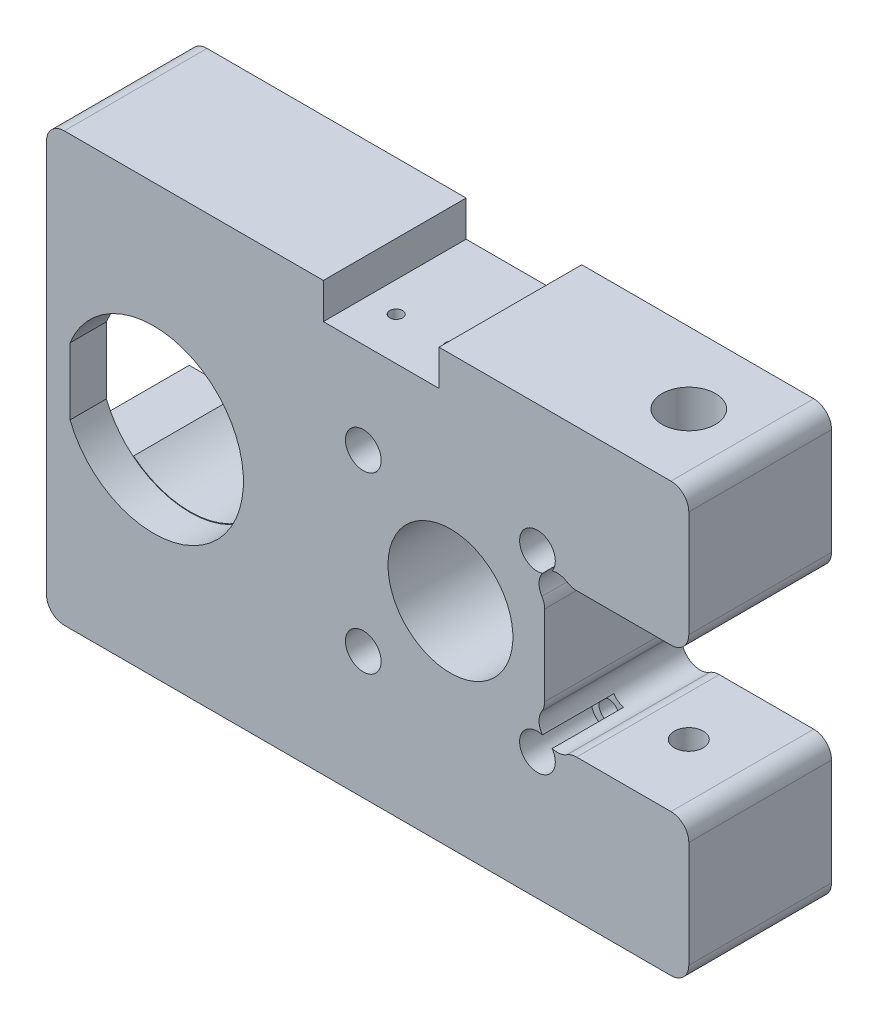
from build123d import *

# Parameters (mm, degrees)
SKETCH1_W           = 114.3
SKETCH1_H           = 76.2
BOSS_EXTRUDE1_DEPTH = 25.4
CUT_EXTRUDE1_DEPTH  = 6.477
CUT_EXTRUDE2_DEPTH  = 18.923
SKETCH4_W           = 20.574
SKETCH4_H           = 25.4
CUT_EXTRUDE3_DEPTH  = 6.35
CUT_EXTRUDE4_START  = -25.4
CUT_EXTRUDE4_DEPTH  = 25.4
CUT_EXTRUDE5_START  = -25.4
SKETCH6_R           = 1.75
SKETCH6_R_2         = 11.1125
CUT_EXTRUDE5_DEPTH  = 25.4
SKETCH8_R           = 3.175
CUT_EXTRUDE6_DEPTH  = 12.7
FILLET1_R           = 3.175
CUT_EXTRUDE7_START  = -76.2
SKETCH9_R           = 2.5796875
CUT_EXTRUDE7_DEPTH  = 76.2
SKETCH10_R          = 4.7625
CUT_EXTRUDE8_DEPTH  = 15.875
SKETCH11_R          = 4.7625
CUT_EXTRUDE9_DEPTH  = 15.875
FILLET2_R           = 3.175
SKETCH12_R          = 2.032
CUT_EXTRUDE10_DEPTH = 12.446
SKETCH13_R          = 1.35255
CUT_EXTRUDE11_DEPTH = 12.7
SKETCH14_R          = 1.143
CUT_EXTRUDE12_DEPTH = 12.7


with BuildPart() as part:
    # Sketch1 → Boss-Extrude1 (new body)
    with BuildSketch(Plane.XY):
        Rectangle(SKETCH1_W, SKETCH1_H)
    extrude(amount=BOSS_EXTRUDE1_DEPTH)

    # Sketch2 → Cut-Extrude1 (cut)
    with BuildSketch(Plane.XY.offset(25.4)):
        with BuildLine():
            Line((-52.959, 5.939202219), (-52.959, -5.939202219))
            ThreePointArc((-52.959, -5.939202219), (-22.098, 0), (-52.959, 5.939202219))
        make_face()
    extrude(amount=-CUT_EXTRUDE1_DEPTH, mode=Mode.SUBTRACT)

    # Sketch3 → Cut-Extrude2 (cut)
    with BuildSketch(Plane.XY.offset(18.923)):
        with BuildLine():
            Line((-17.276835078, 12.319), (-28.067, 12.319))
            ThreePointArc((-28.067, 12.319), (-38.1, 15.887694924), (-48.133, 12.319))
            Line((-48.133, 12.319), (-57.15, 12.319))
            Line((-57.15, 12.319), (-57.15, -12.319))
            Line((-57.15, -12.319), (-48.133, -12.319))
            ThreePointArc((-48.133, -12.319), (-38.1, -15.887694924), (-28.067, -12.319))
            Line((-28.067, -12.319), (-17.276835078, -12.319))
            ThreePointArc((-17.276835078, -12.319), (-12.782632352, -12.236367648), (-12.7, -7.742164922))
            Line((-12.7, -7.742164922), (-12.7, 7.742164922))
            ThreePointArc((-12.7, 7.742164922), (-12.782632352, 12.236367648), (-17.276835078, 12.319))
        make_face()
    extrude(amount=-CUT_EXTRUDE2_DEPTH, mode=Mode.SUBTRACT)

    # Sketch4 → Cut-Extrude3 (cut)
    with BuildSketch(Plane(origin=(0, 38.1, 0), x_dir=(1, 0, 0), z_dir=(0, 1, 0))):
        with Locations((2.413, -12.7)):
            Rectangle(SKETCH4_W, SKETCH4_H)
    extrude(amount=-CUT_EXTRUDE3_DEPTH, mode=Mode.SUBTRACT)

    # Sketch5 → Cut-Extrude4 (cut)
    with BuildSketch(Plane(origin=(0, 0, 0), x_dir=(-1, 0, 0), z_dir=(0, 0, -1)).offset(CUT_EXTRUDE4_START)):
        with BuildLine():
            Line((-36.075066976, -12.827), (-57.15, -12.827))
            Line((-57.15, -12.827), (-57.15, 12.827))
            Line((-57.15, 12.827), (-36.075066976, 12.827))
            ThreePointArc((-36.075066976, 12.827), (-31.451098719, 12.871901281), (-31.496, 8.247933024))
            Line((-31.496, 8.247933024), (-31.496, -8.247933024))
            ThreePointArc((-31.496, -8.247933024), (-31.451098719, -12.871901281), (-36.075066976, -12.827))
        make_face()
    extrude(amount=CUT_EXTRUDE4_DEPTH, mode=Mode.SUBTRACT)

    # Sketch6 → Cut-Extrude5 (cut)
    with BuildSketch(Plane(origin=(0, 0, 0), x_dir=(-1, 0, 0), z_dir=(0, 0, -1)).offset(CUT_EXTRUDE5_START)):
        with Locations((0.768, 15.5)):
            Circle(SKETCH6_R)
        with Locations((0.768, -15.5)):
            Circle(SKETCH6_R)
        with Locations((-14.732, 0)):
            Circle(SKETCH6_R_2)
        with Locations((-30.22, -15.5)):
            Circle(SKETCH6_R)
        with Locations((-30.22, 15.488)):
            Circle(SKETCH6_R)
    extrude(amount=CUT_EXTRUDE5_DEPTH, mode=Mode.SUBTRACT)

    # Sketch8 → Cut-Extrude6 (cut)
    with BuildSketch(Plane.XY.offset(25.4)):
        with Locations((-0.768, -15.5)):
            Circle(SKETCH8_R)
        with Locations((-0.768, 15.5)):
            Circle(SKETCH8_R)
        with Locations((30.22, -15.5)):
            Circle(SKETCH8_R)
        with Locations((30.22, 15.488)):
            Circle(SKETCH8_R)
    extrude(amount=-CUT_EXTRUDE6_DEPTH, mode=Mode.SUBTRACT)

    # Fillet1
    fillet1_edges = [part.edges().sort_by_distance(p)[0] for p in [
        (-57.15, 38.1, 12.7),
        (57.15, 38.1, 12.7),
        (57.15, -38.1, 12.7),
        (-57.15, -38.1, 12.7),
        (57.15, -12.827, 12.7),
        (57.15, 12.827, 12.7),
    ]]
    fillet(fillet1_edges, radius=FILLET1_R)

    # Sketch9 → Cut-Extrude7 (cut)
    with BuildSketch(Plane(origin=(0, 38.1, 0), x_dir=(1, 0, 0), z_dir=(0, 1, 0)).offset(CUT_EXTRUDE7_START)):
        with Locations((44.45, -12.7)):
            Circle(SKETCH9_R)
    extrude(amount=CUT_EXTRUDE7_DEPTH, mode=Mode.SUBTRACT)

    # Sketch10 → Cut-Extrude8 (cut)
    with BuildSketch(Plane(origin=(0, 38.1, 0), x_dir=(1, 0, 0), z_dir=(0, 1, 0))):
        with Locations((44.45, -12.7)):
            Circle(SKETCH10_R)
    extrude(amount=-CUT_EXTRUDE8_DEPTH, mode=Mode.SUBTRACT)

    # Sketch11 → Cut-Extrude9 (cut)
    with BuildSketch(Plane.XZ.offset(38.1)):
        with Locations((44.45, 12.7)):
            Circle(SKETCH11_R)
    extrude(amount=-CUT_EXTRUDE9_DEPTH, mode=Mode.SUBTRACT)

    # Fillet2
    fillet2_edges = [part.edges().sort_by_distance(p)[0] for p in [
        (-17.276835078, 12.319, 9.4615),
        (-12.7, 7.742164922, 9.4615),
        (-12.7, -7.742164922, 9.4615),
        (-17.276835078, -12.319, 9.4615),
        (36.075066976, 12.827, 12.7),
        (31.496, 8.247933024, 12.7),
        (31.496, -8.247933024, 12.7),
        (36.075066976, -12.827, 12.7),
    ]]
    fillet(fillet2_edges, radius=FILLET2_R)

    # Sketch12 → Cut-Extrude10 (cut)
    with BuildSketch(Plane.XZ.offset(38.1)):
        with Locations((-6.35, 12.682334878)):
            Circle(SKETCH12_R)
    extrude(amount=-CUT_EXTRUDE10_DEPTH, mode=Mode.SUBTRACT)

    # Sketch13 → Cut-Extrude11 (cut)
    with BuildSketch(Plane.ZY.offset(57.15)):
        with Locations((12.7, 28.575)):
            Circle(SKETCH13_R)
        with Locations((12.7, -28.575)):
            Circle(SKETCH13_R)
    extrude(amount=-CUT_EXTRUDE11_DEPTH, mode=Mode.SUBTRACT)

    # Sketch14 → Cut-Extrude12 (cut)
    with BuildSketch(Plane(origin=(0, 31.75, 0), x_dir=(1, 0, 0), z_dir=(0, 1, 0))):
        with Locations((-2.54, -17.78)):
            Circle(SKETCH14_R)
        with Locations((7.366, -17.78)):
            Circle(SKETCH14_R)
    extrude(amount=-CUT_EXTRUDE12_DEPTH, mode=Mode.SUBTRACT)


solid = part.part
